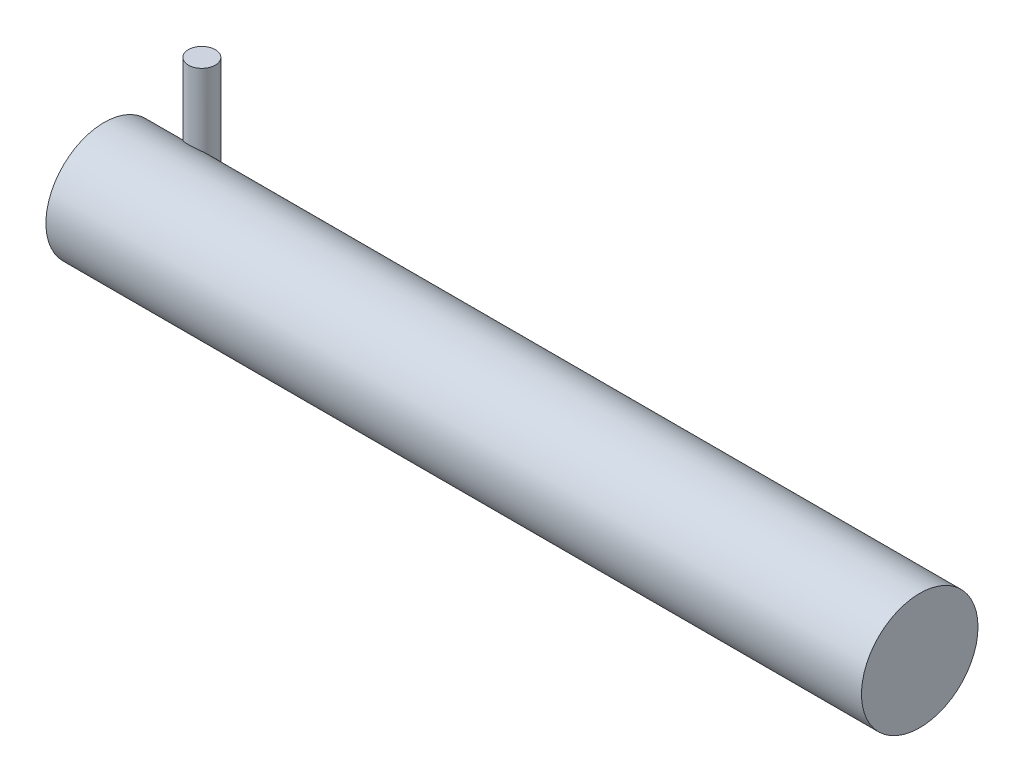
from build123d import *

# Parameters (mm, degrees)
SKETCH1_R           = 5
BOSS_EXTRUDE1_DEPTH = 70
SKETCH2_R           = 1.154484792
BOSS_EXTRUDE2_DEPTH = 10


with BuildPart() as part:
    # Sketch1 → Boss-Extrude1 (new body)
    with BuildSketch(Plane(origin=(0, 0, 0), x_dir=(0, 0, -1), z_dir=(1, 0, 0))):
        Circle(SKETCH1_R)
    extrude(amount=BOSS_EXTRUDE1_DEPTH)

    # Sketch2 → Boss-Extrude2 (add)
    with BuildSketch(Plane(origin=(0, 0, 0), x_dir=(1, 0, 0), z_dir=(0, 1, 0))):
        with Locations((4.359190806, 4.025413268)):
            Circle(SKETCH2_R)
    extrude(amount=BOSS_EXTRUDE2_DEPTH)


solid = part.part
